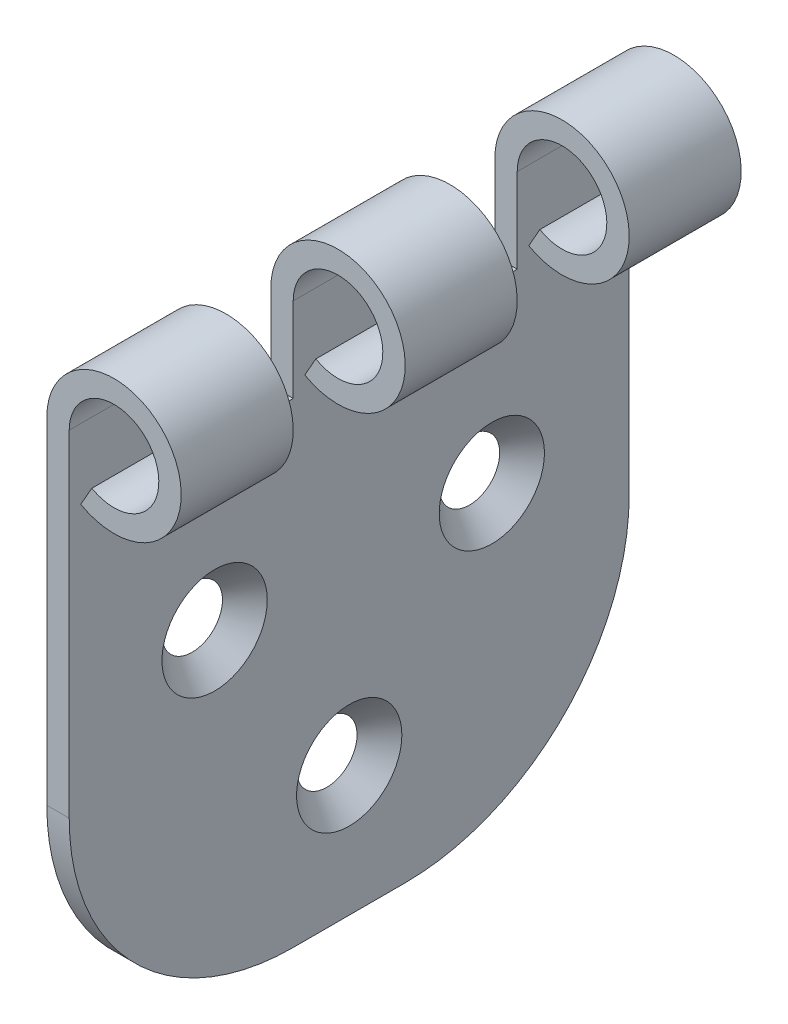
from build123d import *

# Parameters (mm, degrees)
BOSS_EXTRUDE1_DEPTH                          = 25
SKETCH2_W                                    = 10
SKETCH2_H                                    = 20.590421557
CUT_EXTRUDE1_DEPTH                           = 11
CUT_EXTRUDE1_DEPTH_BACK                      = 3
FILLET1_R                                    = 20
CSK_FOR_M4_COUNTERSUNK_FLAT_HEAD_SCR_2_COUNT = 2
CSK_FOR_M4_COUNTERSUNK_FLAT_HEAD_SCR_2_PITCH = 20.373860658
CSK_FOR_M4_COUNTERSUNK_FLAT_HEAD_SCR_3_COUNT = 2
CSK_FOR_M4_COUNTERSUNK_FLAT_HEAD_SCR_3_PITCH = 20.021215351


with BuildPart() as part:
    # Sketch1 → Boss-Extrude1 (new body, symmetric)
    with BuildSketch(Plane.XY):
        with BuildLine():
            Line((0, 0), (0, 50))
            ThreePointArc((0, 50), (11.186683916, 53.016340491), (3.032769985, 44.785065097))
            Line((3.032769985, 44.785065097), (4.021846657, 46.523376732))
            ThreePointArc((4.021846657, 46.523376732), (9.457789277, 52.01089366), (2, 50))
            Line((2, 50), (2, 0))
            Line((2, 0), (0, 0))
        make_face()
    extrude(amount=BOSS_EXTRUDE1_DEPTH, both=True)

    # Sketch2 → Cut-Extrude1 (cut, two sides)
    with BuildSketch(Plane(origin=(2, 0, 0), x_dir=(0, 0, -1), z_dir=(1, 0, 0))) as cut_extrude1_sk:
        with Locations((-10, 52.749880228)):
            Rectangle(SKETCH2_W, SKETCH2_H)
        with Locations((10, 52.749880228)):
            Rectangle(SKETCH2_W, SKETCH2_H)
    extrude(amount=CUT_EXTRUDE1_DEPTH, mode=Mode.SUBTRACT)
    extrude(cut_extrude1_sk.sketch, amount=-CUT_EXTRUDE1_DEPTH_BACK, mode=Mode.SUBTRACT)

    # Fillet1
    fillet1_edges = [part.edges().sort_by_distance(p)[0] for p in [
        (1, 0, 25),
        (1, 0, -25),
    ]]
    fillet(fillet1_edges, radius=FILLET1_R)

    # Sketch4 → CSK for M4 Countersunk Flat Head Screw1 (revolve, cut)
    with BuildSketch(Plane(origin=(2, 11.587467643, 0), x_dir=(0, 0, -1), z_dir=(0, 1, 0))):
        Polygon((0, 0), (0, 2), (2.25, 2), (2.25, 2.45), (4.7, 0), align=None)
    csk_for_m4_countersunk_flat_head_screw1 = revolve(axis=Axis((8.35, 11.587467643, 0), (-1, 0, 0)), mode=Mode.SUBTRACT)

    # CSK for M4 Countersunk Flat Head Scr 2: CSK for M4 Countersunk Flat Head Screw1 ×2
    with Locations(*[Vector(0, 0.807519759, 0.58984052) * (i * CSK_FOR_M4_COUNTERSUNK_FLAT_HEAD_SCR_2_PITCH) for i in range(1, CSK_FOR_M4_COUNTERSUNK_FLAT_HEAD_SCR_2_COUNT)]):
        add(csk_for_m4_countersunk_flat_head_screw1, mode=Mode.SUBTRACT)

    # CSK for M4 Countersunk Flat Head Scr 3: CSK for M4 Countersunk Flat Head Screw1 ×2
    with Locations(*[Vector(0, 0.77172393, -0.635957683) * (i * CSK_FOR_M4_COUNTERSUNK_FLAT_HEAD_SCR_3_PITCH) for i in range(1, CSK_FOR_M4_COUNTERSUNK_FLAT_HEAD_SCR_3_COUNT)]):
        add(csk_for_m4_countersunk_flat_head_screw1, mode=Mode.SUBTRACT)


solid = part.part
